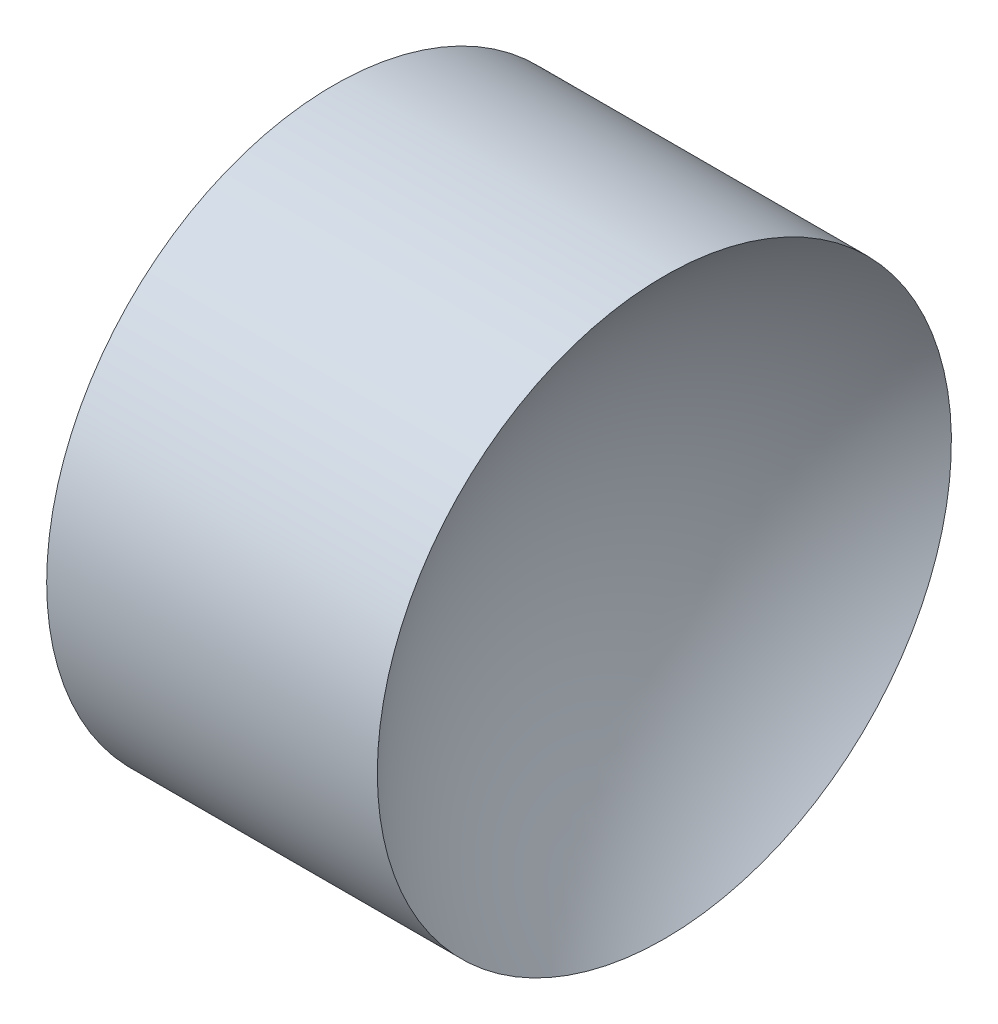
from build123d import *


with BuildPart() as part:
    # 草图1 → 旋转1 (revolve)
    with BuildSketch(Plane.XY, mode=Mode.PRIVATE) as revolve_1_sk:
        with BuildLine():
            Line((11.080595085, 6.515563046), (11.080595085, 8.515563046))
            Line((11.080595085, 8.515563046), (13.384426348, 8.515563046))
            ThreePointArc((13.384426348, 8.515563046), (12.789072416, 7.593308922), (12.580595085, 6.515563046))
            Line((12.580595085, 6.515563046), (11.080595085, 6.515563046))
        make_face()
    revolve(revolve_1_sk.sketch.rotate(Axis((10.578235961, 6.515563046, 0), (1, 0, 0)), 180), axis=Axis((10.578235961, 6.515563046, 0), (1, 0, 0)))  # turned: the seam where the file's is


solid = part.part
